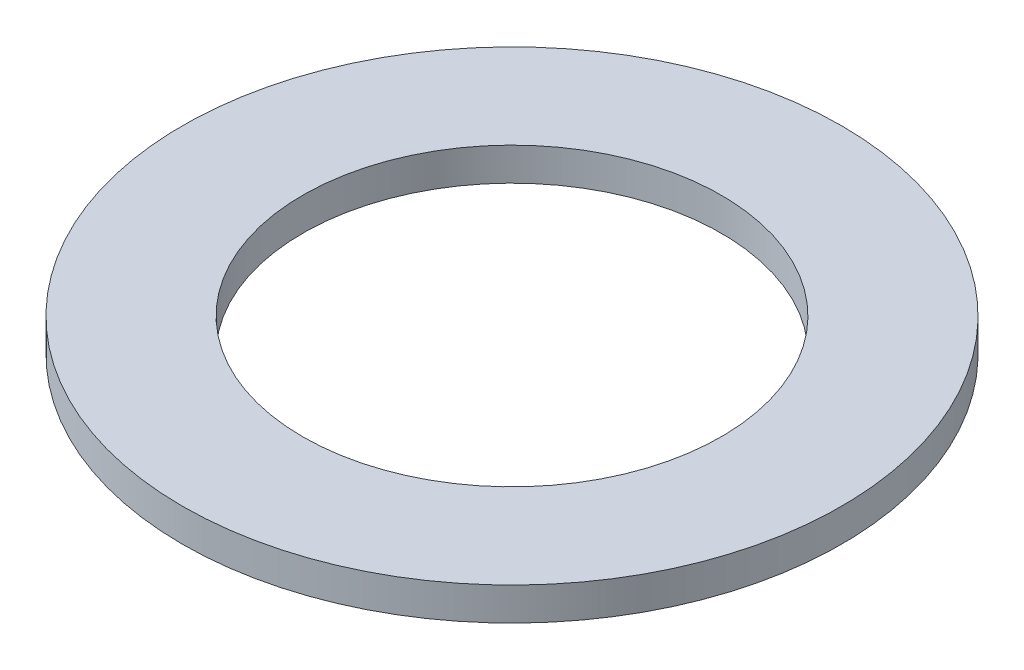
from build123d import *

# Parameters (mm, degrees)
CROQUIS1_R              = 30
CROQUIS1_R_2            = 19.05
SALIENTE_EXTRUIR1_DEPTH = 3


with BuildPart() as part:
    # Croquis1 → Saliente-Extruir1 (new body)
    with BuildSketch(Plane(origin=(0, 0, 0), x_dir=(1, 0, 0), z_dir=(0, 1, 0))):
        Circle(CROQUIS1_R)
        Circle(CROQUIS1_R_2, mode=Mode.SUBTRACT)
    extrude(amount=SALIENTE_EXTRUIR1_DEPTH)


solid = part.part
